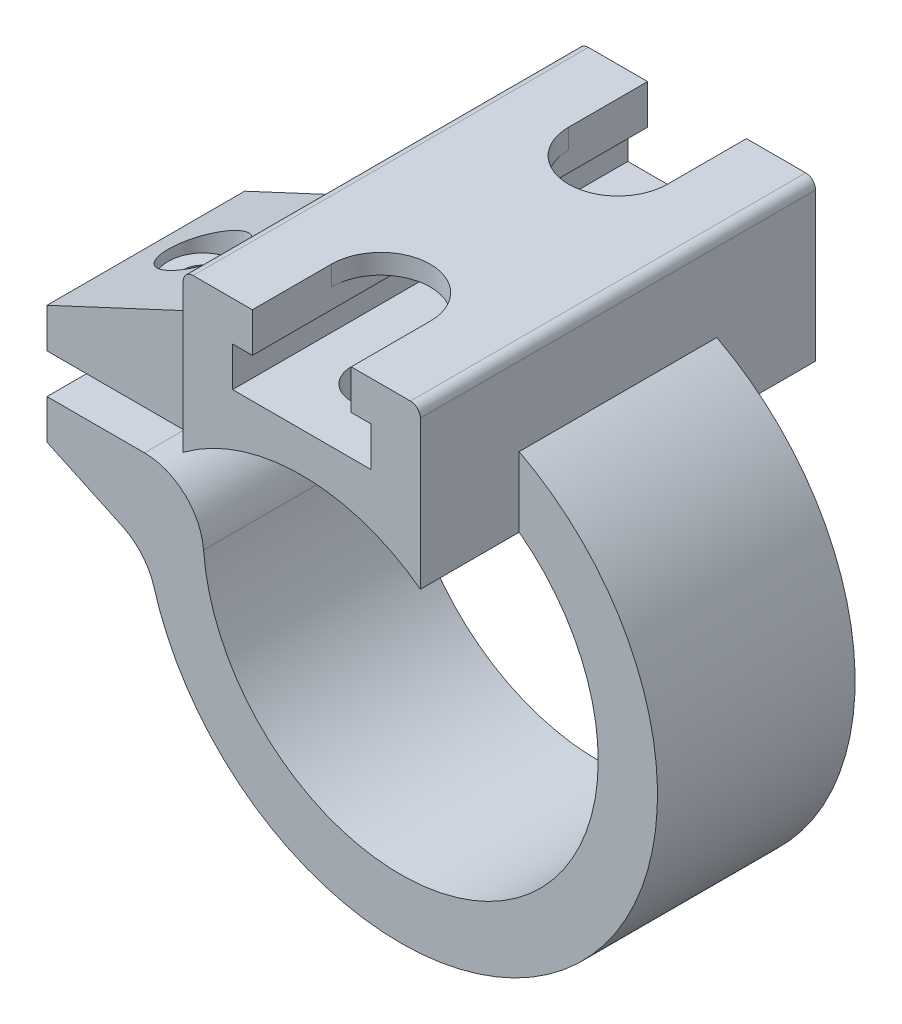
from build123d import *
from build123d.topology import SkipClean

# Parameters (mm, degrees)
BOSS_EXTRUDE1_DEPTH     = 5
CUT_EXTRUDE1_DEPTH      = 11
BOSS_EXTRUDE2_DEPTH     = 10
CUT_EXTRUDE2_DEPTH      = 21
CUT_EXTRUDE3_REACH      = 31
CUT_EXTRUDE4_REACH      = 27
CUT_EXTRUDE4_END_RADIUS = 10
SKETCH6_R               = 1.5
SKETCH9_R               = 1.75
CUT_EXTRUDE7_DEPTH      = 10
SKETCH10_R              = 1
CUT_EXTRUDE6_DEPTH      = 30
FILLET9_R               = 3


with BuildPart() as part:
    # Sketch1 → Boss-Extrude1 (new body, symmetric)
    with BuildSketch(Plane.XY):
        with BuildLine():
            Line((-17.893579058, 0), (-12.779389539, -2.384785738))
            ThreePointArc((-12.779389539, -2.384785738), (11.560882159, -5.945250516), (-5.494037403, 11.782001231))
            Line((-5.494037403, 11.782001231), (-17.893579058, 6))
            Line((-17.893579058, 6), (-17.893579058, 0))
        make_face()
    extrude(amount=BOSS_EXTRUDE1_DEPTH, both=True)

    # Sketch2 → Cut-Extrude1 (cut, through all)
    with BuildSketch(Plane.XY.offset(5)):
        with BuildLine():
            Line((-17.893579058, 4), (-10.95445115, 4))
            ThreePointArc((-10.95445115, 4), (-9.513297766, 4.368825942), (-8.426500885, 5.384615385))
            ThreePointArc((-8.426500885, 5.384615385), (9.699416117, -2.43337769), (-9.970370305, -0.769230769))
            ThreePointArc((-9.970370305, -0.769230769), (-10.923382735, 1.201398157), (-12.961481397, 2))
            Line((-12.961481397, 2), (-17.893579058, 2))
            Line((-17.893579058, 2), (-17.893579058, 4))
        make_face()
    extrude(amount=-CUT_EXTRUDE1_DEPTH, mode=Mode.SUBTRACT)

    # Sketch3 → Boss-Extrude2 (add, symmetric)
    with SkipClean():  # keep this step's faces unmerged: merging them makes the solid invalid here
        with BuildSketch(Plane.XY):
            with BuildLine():
                Line((-5.5, 16), (5.5, 16))
                ThreePointArc((5.5, 16), (5.853553391, 15.853553391), (6, 15.5))
                Line((6, 15.5), (6, 8))
                ThreePointArc((6, 8), (0, 10), (-6, 8))
                Line((-6, 8), (-6, 15.5))
                ThreePointArc((-6, 15.5), (-5.853553391, 15.853553391), (-5.5, 16))
            make_face()
        extrude(amount=BOSS_EXTRUDE2_DEPTH, both=True)

    # Sketch4 → Cut-Extrude2 (cut, through all)
    with SkipClean():  # keep this step's faces unmerged: merging them makes the solid invalid here
        with BuildSketch(Plane.XY.offset(10)):
            Polygon((-2.5, 15), (2.5, 15), (2.5, 14), (3.5, 14), (3.5, 12), (-3.5, 12), (-3.5, 14), (-2.5, 14), align=None)
        extrude(amount=-CUT_EXTRUDE2_DEPTH, mode=Mode.SUBTRACT)

    # Sketch5 → Cut-Extrude3 (cut, up to next)
    with BuildSketch(Plane(origin=(0, 16, 0), x_dir=(1, 0, 0), z_dir=(0, 1, 0)), mode=Mode.PRIVATE) as cut_extrude3_sk1:
        with BuildLine():
            Line((-2.5, 6), (-2.5, 10))
            Line((-2.5, 10), (2.5, 10))
            Line((2.5, 10), (2.5, 6))
            ThreePointArc((2.5, 6), (0, 3.5), (-2.5, 6))
        make_face()
    cut_extrude3_tool1 = extrude(cut_extrude3_sk1.sketch, amount=-CUT_EXTRUDE3_REACH, mode=Mode.PRIVATE) & part.part
    add(cut_extrude3_tool1.solids().sort_by_distance((0, 16, -6.992147))[0], mode=Mode.SUBTRACT)
    # Sketch5 → Cut-Extrude3 (cut, up to next)
    with BuildSketch(Plane(origin=(0, 16, 0), x_dir=(1, 0, 0), z_dir=(0, 1, 0)), mode=Mode.PRIVATE) as cut_extrude3_sk2:
        with BuildLine():
            Line((2.5, -10), (2.5, -6))
            ThreePointArc((2.5, -6), (0, -3.5), (-2.5, -6))
            Line((-2.5, -6), (-2.5, -10))
            Line((-2.5, -10), (2.5, -10))
        make_face()
    cut_extrude3_tool2 = extrude(cut_extrude3_sk2.sketch, amount=-CUT_EXTRUDE3_REACH, mode=Mode.PRIVATE) & part.part
    add(cut_extrude3_tool2.solids().sort_by_distance((0, 16, 6.992147))[0], mode=Mode.SUBTRACT)

    # Cut-Extrude4: up to this cylinder (the profile starts outside it)
    cut_extrude4_end = Plane(origin=(0, 0, 0), z_dir=(0, 0, 1)) * Cylinder(CUT_EXTRUDE4_END_RADIUS, 87, mode=Mode.PRIVATE)
    # Sketch6 → Cut-Extrude4 (cut, up to the surface)
    with BuildSketch(Plane(origin=(0, 12, 0), x_dir=(1, 0, 0), z_dir=(0, 1, 0)), mode=Mode.PRIVATE) as cut_extrude4_sk1:
        with Locations(Location((0, 6, 0), (0, 0, 270))):  # turned: the seam where the file's is
            Circle(SKETCH6_R)
    cut_extrude4_tool1 = extrude(cut_extrude4_sk1.sketch, amount=-CUT_EXTRUDE4_REACH, mode=Mode.PRIVATE) - cut_extrude4_end
    add(cut_extrude4_tool1.solids().sort_by_distance((0, 12, -6))[0], mode=Mode.SUBTRACT)
    # Sketch6 → Cut-Extrude4 (cut, up to the surface)
    with BuildSketch(Plane(origin=(0, 12, 0), x_dir=(1, 0, 0), z_dir=(0, 1, 0)), mode=Mode.PRIVATE) as cut_extrude4_sk2:
        with Locations(Location((0, -6, 0), (0, 0, 270))):  # turned: the seam where the file's is
            Circle(SKETCH6_R)
    cut_extrude4_tool2 = extrude(cut_extrude4_sk2.sketch, amount=-CUT_EXTRUDE4_REACH, mode=Mode.PRIVATE) - cut_extrude4_end
    add(cut_extrude4_tool2.solids().sort_by_distance((0, 12, 6))[0], mode=Mode.SUBTRACT)

    # Sketch9 → Cut-Extrude7 (cut)
    with BuildSketch(Plane(origin=(0, 16, 0), x_dir=(1, 0, 0), z_dir=(0, 1, 0))):
        with Locations(Location((-15, 0, 0), (0, 0, 270))):  # turned: the seam where the file's is
            Circle(SKETCH9_R)
    extrude(amount=-CUT_EXTRUDE7_DEPTH, mode=Mode.SUBTRACT)

    # Sketch10 → Cut-Extrude6 (cut, through all)
    with BuildSketch(Plane(origin=(0, 16, 0), x_dir=(1, 0, 0), z_dir=(0, 1, 0))):
        with Locations(Location((-15, 0, 0), (0, 0, 270))):  # turned: the seam where the file's is
            Circle(SKETCH10_R)
    extrude(amount=-CUT_EXTRUDE6_DEPTH, mode=Mode.SUBTRACT)

    # Fillet9
    fillet9_edges = [part.edges().sort_by_distance(p)[0] for p in [
        (-12.779389539, -2.384785738, 0),
    ]]
    fillet(fillet9_edges, radius=FILLET9_R)


solid = part.part
